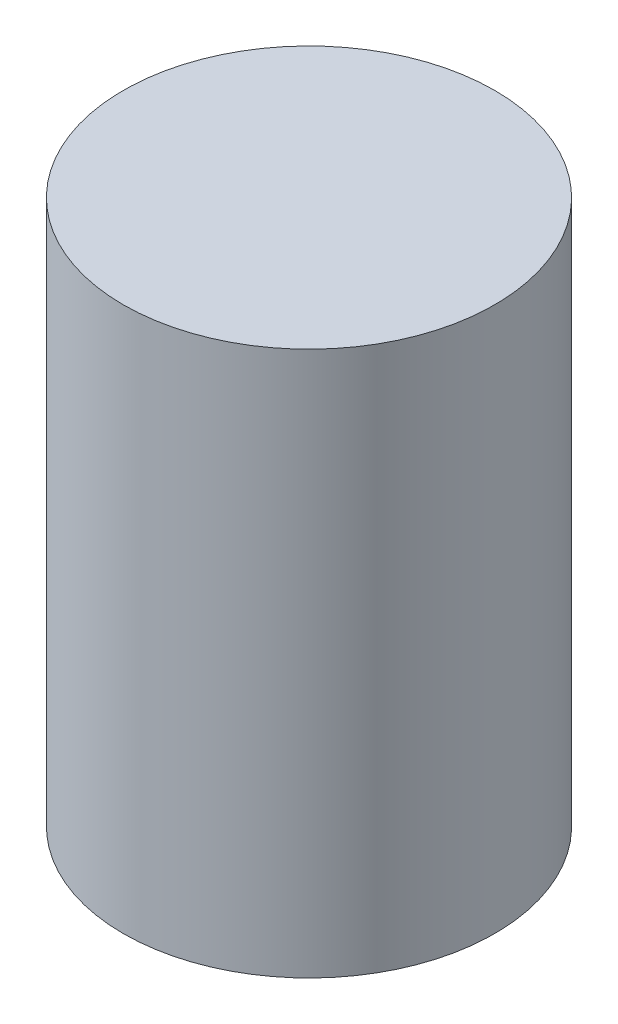
from build123d import *

# Parameters (mm, degrees)
SKETCH1_R           = 11
BOSS_EXTRUDE1_DEPTH = 32.26


with BuildPart() as part:
    # Sketch1 → Boss-Extrude1 (new body)
    with BuildSketch(Plane(origin=(0, 0, 0), x_dir=(1, 0, 0), z_dir=(0, 1, 0))):
        with Locations((-15.32076311, 23.227019559)):
            Circle(SKETCH1_R)
    extrude(amount=BOSS_EXTRUDE1_DEPTH)


solid = part.part
